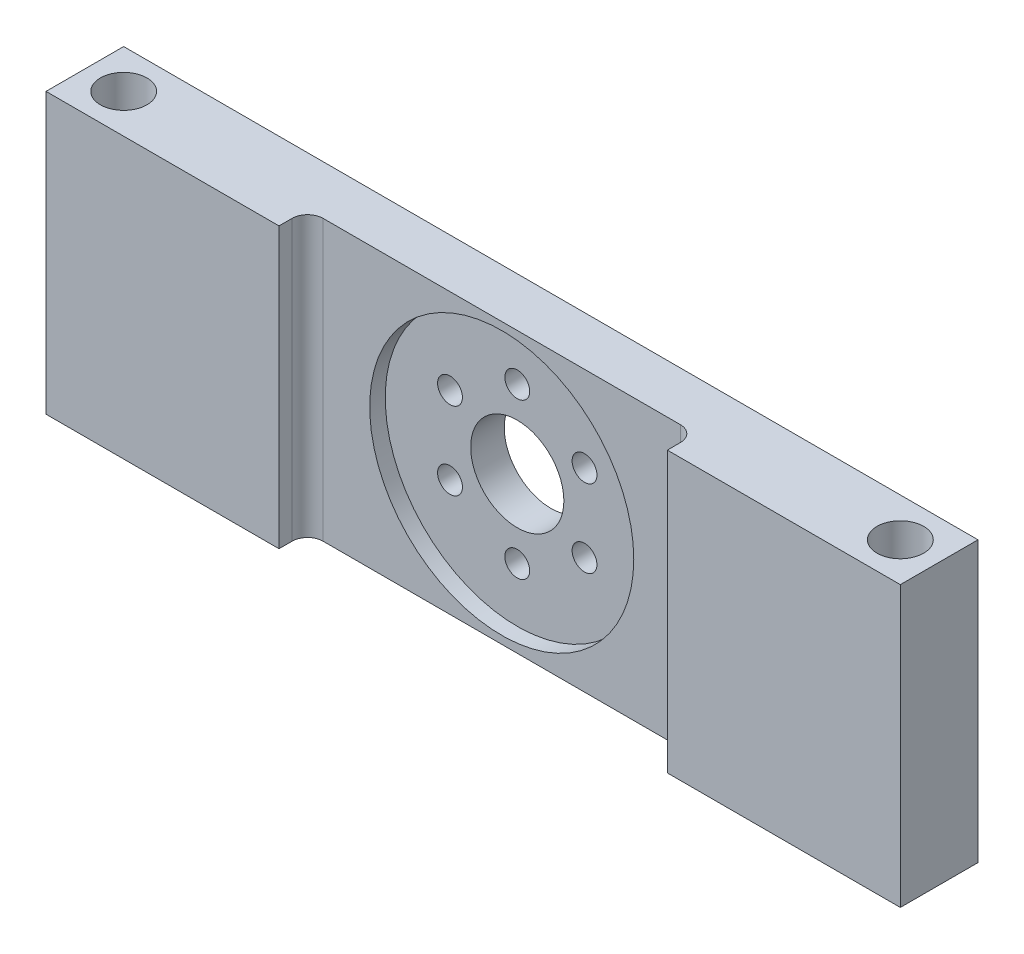
from build123d import *

# Parameters (mm, degrees)
BOSS_EXTRUDE1_DEPTH = 18
SKETCH9_R           = 8.5
CUT_EXTRUDE6_DEPTH  = 1
SKETCH10_R          = 3
CUT_EXTRUDE7_DEPTH  = 3.161013299
SKETCH11_R          = 0.8
CUT_EXTRUDE8_DEPTH  = 3.161013299
FILLET1_R           = 1
SKETCH13_R          = 1.5
CUT_EXTRUDE10_DEPTH = 19


with BuildPart() as part:
    # Sketch2 → Boss-Extrude1 (new body)
    with BuildSketch(Plane(origin=(0, 0, 0), x_dir=(1, 0, 0), z_dir=(0, 1, 0))):
        Polygon((-33.940224132, -1.838986701), (-18.940224132, -1.838986701), (-18.940224132, 3.161013299), (-73.940224132, 3.161013299), (-73.940224132, -1.838986701), (-58.940224132, -1.838986701), (-58.940224132, 0), (-33.940224132, 0), align=None)
    extrude(amount=BOSS_EXTRUDE1_DEPTH)

    # Sketch9 → Cut-Extrude6 (cut)
    with BuildSketch(Plane.XY):
        with Locations((-46.440224132, 9)):
            Circle(SKETCH9_R)
    extrude(amount=-CUT_EXTRUDE6_DEPTH, mode=Mode.SUBTRACT)

    # Sketch10 → Cut-Extrude7 (cut, through all)
    with BuildSketch(Plane.XY.offset(-1)):
        with Locations((-46.440224132, 9)):
            Circle(SKETCH10_R)
    extrude(amount=-CUT_EXTRUDE7_DEPTH, mode=Mode.SUBTRACT)

    # Sketch11 → Cut-Extrude8 (cut, through all)
    with BuildSketch(Plane.XY.offset(-1)):
        with Locations((-42.110097113, 11.5)):
            Circle(SKETCH11_R)
        with Locations((-42.110097113, 6.5)):
            Circle(SKETCH11_R)
        with Locations((-46.440224132, 14)):
            Circle(SKETCH11_R)
        with Locations((-46.440224132, 4)):
            Circle(SKETCH11_R)
        with Locations((-50.770351151, 11.5)):
            Circle(SKETCH11_R)
        with Locations((-50.770351151, 6.5)):
            Circle(SKETCH11_R)
    extrude(amount=-CUT_EXTRUDE8_DEPTH, mode=Mode.SUBTRACT)

    # Fillet1
    fillet1_edges = [part.edges().sort_by_distance(p)[0] for p in [
        (-33.940224132, 9, 0),
        (-58.940224132, 9, 0),
    ]]
    fillet(fillet1_edges, radius=FILLET1_R)

    # Sketch13 → Cut-Extrude10 (cut, through all)
    with BuildSketch(Plane(origin=(0, 18, 0), x_dir=(1, 0, 0), z_dir=(0, 1, 0))):
        with Locations((-71.440224132, 0.661013299)):
            Circle(SKETCH13_R)
        with Locations((-21.440224132, 0.661013299)):
            Circle(SKETCH13_R)
    extrude(amount=-CUT_EXTRUDE10_DEPTH, mode=Mode.SUBTRACT)


solid = part.part
